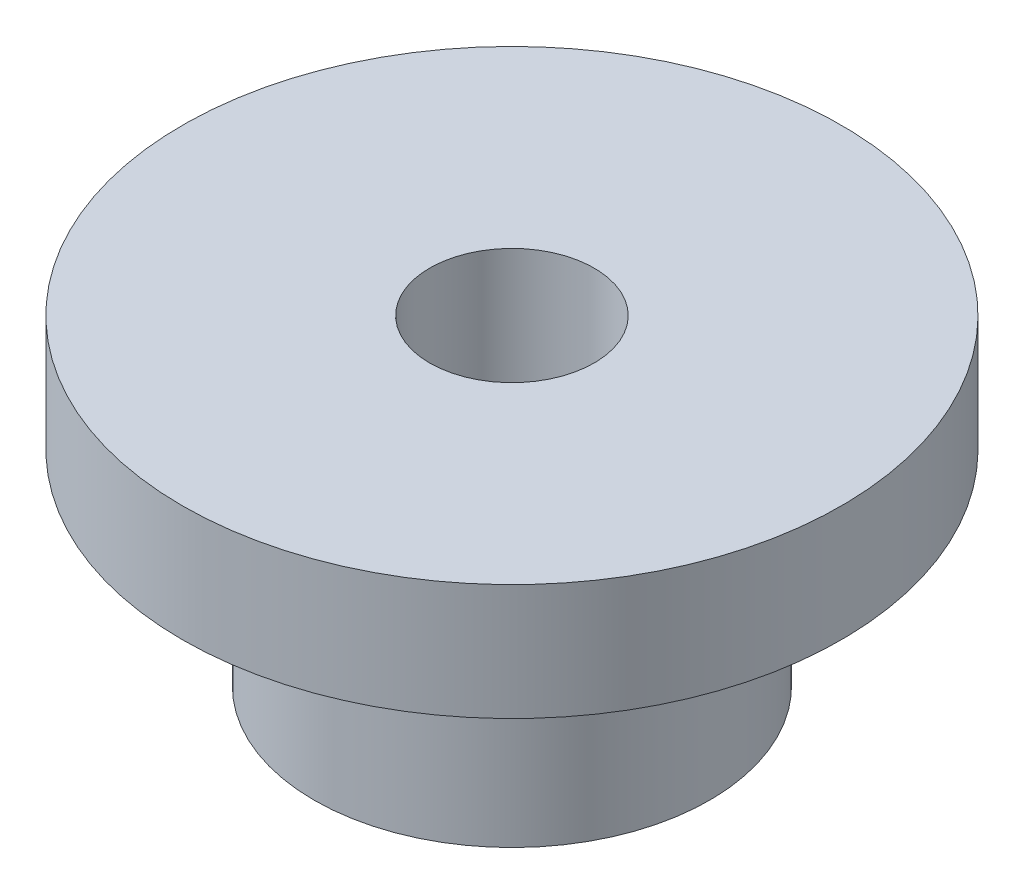
from build123d import *

# Parameters (mm, degrees)
SKETCH1_R      = 4.7625
SKETCH1_R_2    = 1.9812
EXTRUDE1_DEPTH = 4.93522
SKETCH2_R      = 7.9375
SKETCH2_R_2    = 1.9812
EXTRUDE2_DEPTH = 2.794


with BuildPart() as part:
    # Sketch1 → Extrude1 (new body)
    with BuildSketch(Plane(origin=(0, 0, 0), x_dir=(1, 0, 0), z_dir=(0, 1, 0))):
        Circle(SKETCH1_R)
        Circle(SKETCH1_R_2, mode=Mode.SUBTRACT)
    extrude(amount=EXTRUDE1_DEPTH)

    # Sketch2 → Extrude2 (add)
    with BuildSketch(Plane(origin=(0, 4.93522, 0), x_dir=(-1, 0, 0), z_dir=(0, 1, 0))):
        Circle(SKETCH2_R)
        Circle(SKETCH2_R_2, mode=Mode.SUBTRACT)
    extrude(amount=EXTRUDE2_DEPTH)


solid = part.part
